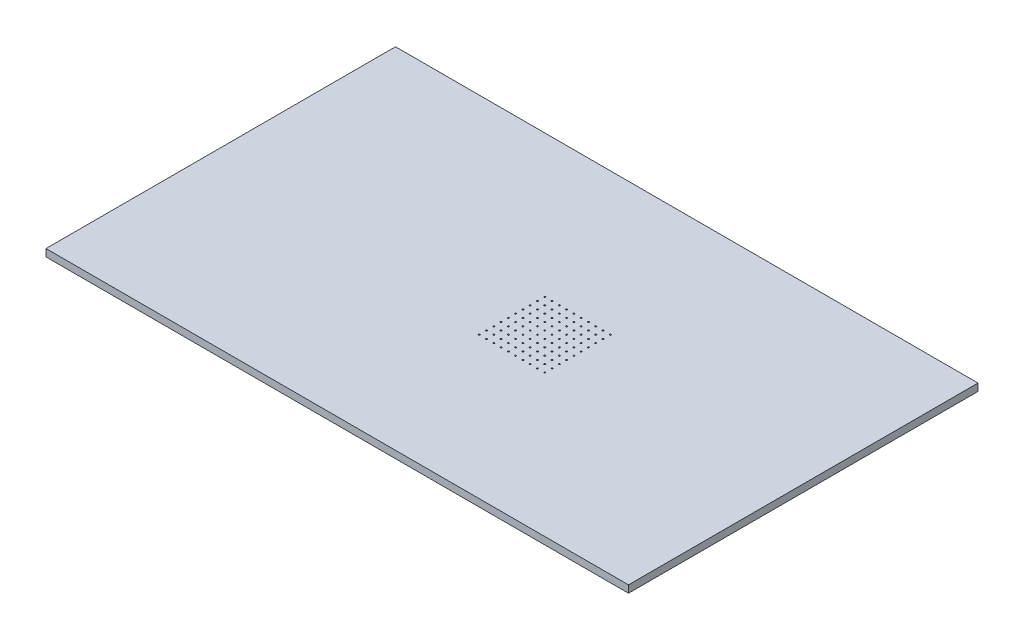
from build123d import *

# Parameters (mm, degrees)
SKETCH2_W               = 2032
SKETCH2_H               = 1219.2
BOSS_EXTRUDE1_DEPTH     = 25.4
F_1_4_20_TAPPED_HOLE1_D = 5.1054
LPATTERN1_COUNT         = 10
LPATTERN1_PITCH         = 25.4
LPATTERN1_COUNT_DIR2    = 10
LPATTERN1_PITCH_DIR2    = 25.4


with BuildPart() as part:
    # Sketch2 → Boss-Extrude1 (new body)
    with BuildSketch(Plane(origin=(0, 0, 0), x_dir=(1, 0, 0), z_dir=(0, 1, 0))):
        with Locations((-1835.727272727, 925.945454545)):
            Rectangle(SKETCH2_W, SKETCH2_H)
    extrude(amount=BOSS_EXTRUDE1_DEPTH)

    # 1/4-20 Tapped Hole1 (through all)
    with Locations(Plane(origin=(0, 25.4, 0), x_dir=(1, 0, 0), z_dir=(0, 1, 0))):
        with Locations((-1835.727272727, 811.645454545)):
            f_1_4_20_tapped_hole1 = Hole(F_1_4_20_TAPPED_HOLE1_D / 2)

    # LPattern1: 1_4-20 Tapped Hole1 10 × 10
    with Locations(*[(j * LPATTERN1_PITCH_DIR2, 0, -i * LPATTERN1_PITCH) for i in range(LPATTERN1_COUNT) for j in range(LPATTERN1_COUNT_DIR2) if (i, j) != (0, 0)]):
        add(f_1_4_20_tapped_hole1, mode=Mode.SUBTRACT)


solid = part.part
